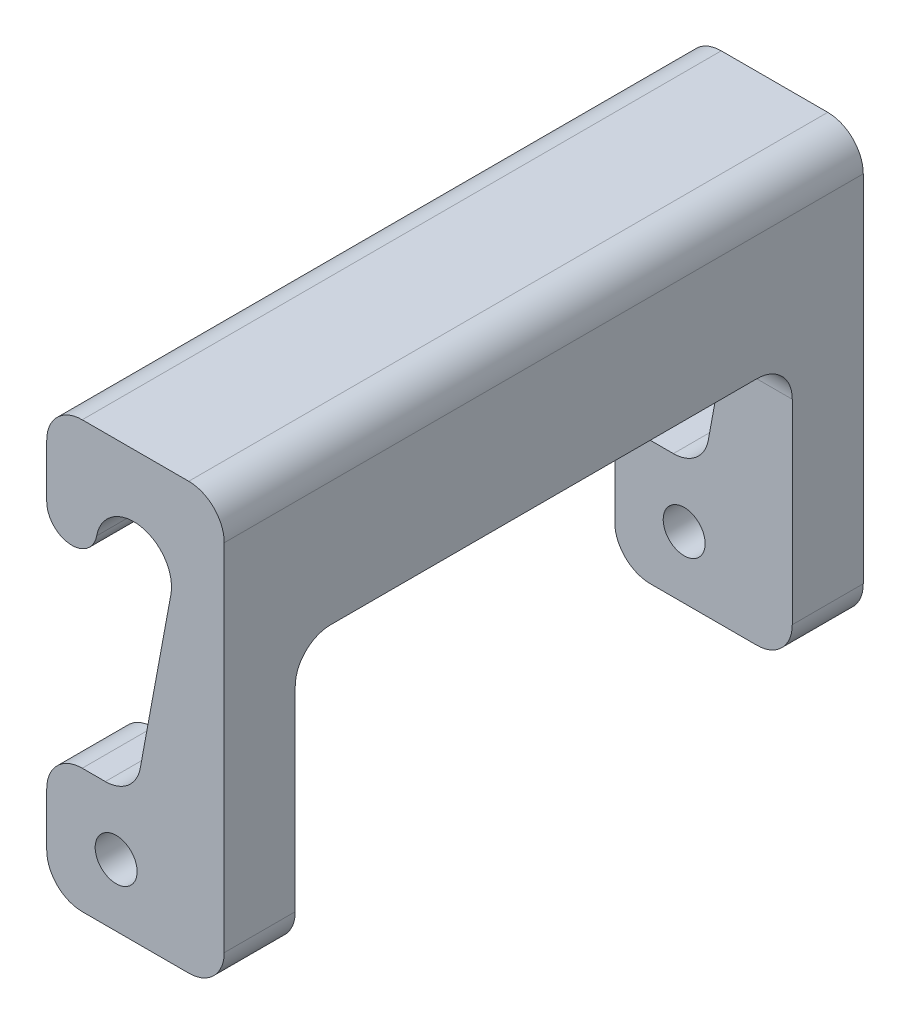
from build123d import *

# Parameters (mm, degrees)
SKETCH1_R           = 1.5
BOSS_EXTRUDE1_DEPTH = 45.72
CUT_EXTRUDE1_DEPTH  = 25.4


with BuildPart() as part:
    # Sketch1 → Boss-Extrude1 (new body)
    with BuildSketch(Plane.XY):
        with BuildLine():
            Line((8.882163561, 22.821280576), (6.691616477, 10.968396178))
            ThreePointArc((6.691616477, 10.968396178), (5.818586392, 9.477556184), (4.19391315, 8.89))
            Line((4.19391315, 8.89), (2.54, 8.89))
            ThreePointArc((2.54, 8.89), (0.743948776, 8.146051224), (0, 6.35))
            Line((0, 6.35), (0, 2.54))
            ThreePointArc((0, 2.54), (0.743948776, 0.743948776), (2.54, 0))
            Line((2.54, 0), (10.16, 0))
            ThreePointArc((10.16, 0), (11.956051224, 0.743948776), (12.7, 2.54))
            Line((12.7, 2.54), (12.7, 27.94))
            ThreePointArc((12.7, 27.94), (11.956051224, 29.736051224), (10.16, 30.48))
            Line((10.16, 30.48), (2.54, 30.48))
            ThreePointArc((2.54, 30.48), (0.743948776, 29.736051224), (0, 27.94))
            Line((0, 27.94), (0, 24.13))
            ThreePointArc((0, 24.13), (1.636464911, 22.336730574), (3.571576672, 23.802737092))
            ThreePointArc((3.571576672, 23.802737092), (6.717598374, 25.967302278), (8.882163561, 22.821280576))
        make_face()
        with Locations((4.965459901, 4.445)):
            Circle(SKETCH1_R, mode=Mode.SUBTRACT)
    extrude(amount=BOSS_EXTRUDE1_DEPTH)

    # Sketch2 → Cut-Extrude1 (cut)
    with BuildSketch(Plane(origin=(12.7, 0, 0), x_dir=(0, 0, -1), z_dir=(1, 0, 0))):
        with BuildLine():
            Line((-40.64, 0), (-5.08, 0))
            Line((-5.08, 0), (-5.08, 16.51))
            ThreePointArc((-5.08, 16.51), (-5.823948776, 18.306051224), (-7.62, 19.05))
            Line((-7.62, 19.05), (-38.1, 19.05))
            ThreePointArc((-38.1, 19.05), (-39.896051224, 18.306051224), (-40.64, 16.51))
            Line((-40.64, 16.51), (-40.64, 0))
        make_face()
    extrude(amount=-CUT_EXTRUDE1_DEPTH, mode=Mode.SUBTRACT)


solid = part.part
